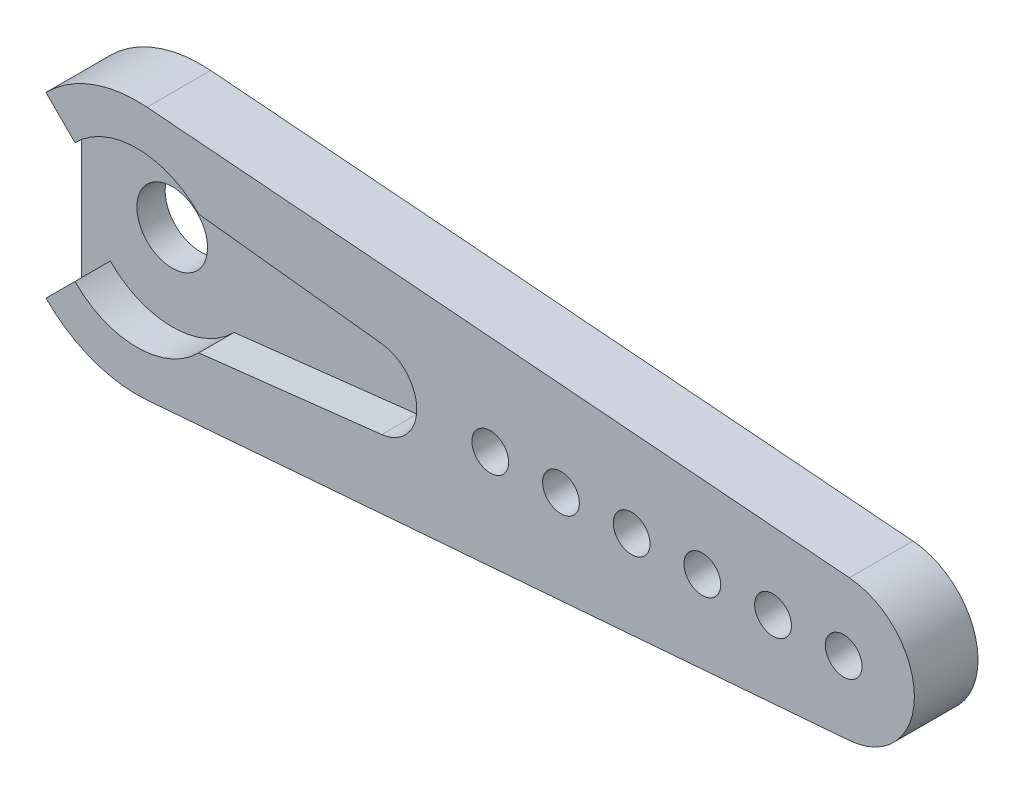
from build123d import *

# Parameters (mm, degrees)
MAIN_DEPTH            = 2.5
ESQUISSE2_R           = 2.5
ORIGINALBRACKET_DEPTH = 2
ESQUISSE3_R           = 1.3
FIXINGHOLE_DEPTH      = 5.5
LPATTERN1_COUNT       = 6
LPATTERN1_PITCH       = 5


with BuildPart() as part:
    # Esquisse1 → Main (new body)
    with BuildSketch(Plane.XY):
        with BuildLine():
            Line((-4.375785644, 4.25), (-6.426543071, 6.300757427))
            ThreePointArc((-6.426543071, 6.300757427), (-3.150224217, 8.43066352), (0.72, 8.971153772))
            Line((0.72, 8.971153772), (50.4, 4.983974318))
            ThreePointArc((50.4, 4.983974318), (55, 0), (50.4, -4.983974318))
            Line((50.4, -4.983974318), (0.72, -8.971153772))
            ThreePointArc((0.72, -8.971153772), (-3.150224217, -8.43066352), (-6.426543071, -6.300757427))
            Line((-6.426543071, -6.300757427), (-4.375785644, -4.25))
            ThreePointArc((-4.375785644, -4.25), (0, -6.1), (4.375785644, -4.25))
            Line((4.375785644, -4.25), (17.31559729, -2.78215714))
            ThreePointArc((17.31559729, -2.78215714), (19.8, 0), (17.31559729, 2.78215714))
            Line((17.31559729, 2.78215714), (4.375785644, 4.25))
            ThreePointArc((4.375785644, 4.25), (0, 6.1), (-4.375785644, 4.25))
        make_face()
    extrude(amount=MAIN_DEPTH)

    # Esquisse2 → OriginalBracket (add)
    with BuildSketch(Plane(origin=(0, 0, 0), x_dir=(-1, 0, 0), z_dir=(0, 0, -1))):
        with BuildLine():
            Line((-0.72, -8.971153772), (-50.4, -4.983974318))
            ThreePointArc((-50.4, -4.983974318), (-55, 0), (-50.4, 4.983974318))
            Line((-50.4, 4.983974318), (-0.72, 8.971153772))
            ThreePointArc((-0.72, 8.971153772), (3.150224217, 8.43066352), (6.426543071, 6.300757427))
            Line((6.426543071, 6.300757427), (6.426543071, -6.300757427))
            ThreePointArc((6.426543071, -6.300757427), (3.150224217, -8.43066352), (-0.72, -8.971153772))
        make_face()
        Circle(ESQUISSE2_R, mode=Mode.SUBTRACT)
    extrude(amount=ORIGINALBRACKET_DEPTH)

    # Esquisse3 → FixingHole (cut, through all)
    with BuildSketch(Plane.XY.offset(2.5)):
        with Locations((50, 0)):
            Circle(ESQUISSE3_R)
    fixinghole = extrude(amount=-FIXINGHOLE_DEPTH, mode=Mode.SUBTRACT)

    # LPattern1: FixingHole ×6
    with Locations(*[(-i * LPATTERN1_PITCH, 0, 0) for i in range(1, LPATTERN1_COUNT)]):
        add(fixinghole, mode=Mode.SUBTRACT)


solid = part.part
